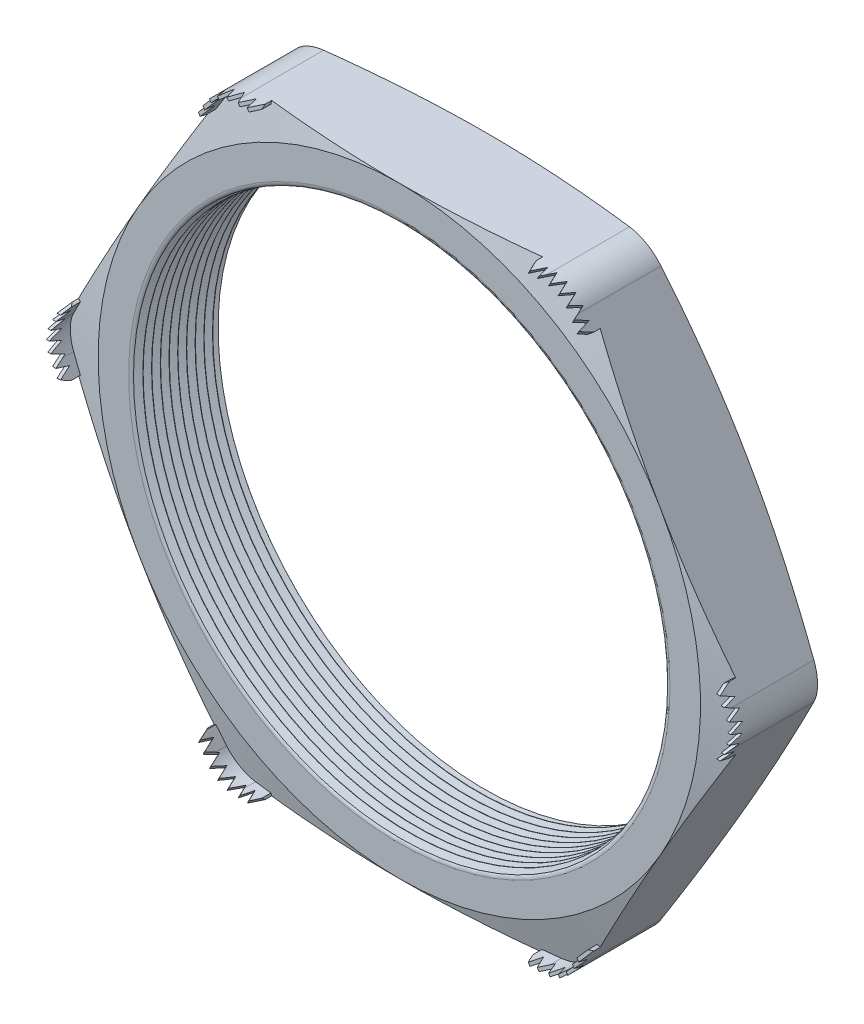
from build123d import *

# Parameters (mm, degrees)
SKETCH1_R          = 9.271
EXTRUDE1_DEPTH     = 3.048
FILLET1_R          = 1.27
FILLET3_R          = 0.2032
LPATTERN1_COUNT    = 10
LPATTERN1_PITCH    = 0.3048
SKETCH4_OUTSIDE_W  = 62.576
SKETCH4_OUTSIDE_H  = 59.708
SKETCH4_OUTSIDE_R  = 10.541
CUT_EXTRUDE1_DEPTH = 4.048
CUT_EXTRUDE1_DRAFT = -75
SKETCH5_OUTSIDE_W  = 62.576
SKETCH5_OUTSIDE_H  = 59.708
SKETCH5_OUTSIDE_R  = 10.541
CUT_EXTRUDE2_DEPTH = 4.0480001
CUT_EXTRUDE2_DRAFT = -75
EXTRUDE2_START     = -0.384301
EXTRUDE2_DEPTH     = 1.400301
CUT_EXTRUDE4_DEPTH = 4.70409549
CIRPATTERN1_COUNT  = 6
CIRPATTERN2_COUNT  = 6


with BuildPart() as part:
    # Sketch1 → Extrude1 (new body)
    with BuildSketch(Plane.XY):
        Polygon((-12.171698375, 0), (-6.085849188, -10.541), (6.085849188, -10.541), (12.171698375, 0), (6.085849188, 10.541), (-6.085849188, 10.541), align=None)
        Circle(SKETCH1_R, mode=Mode.SUBTRACT)
    extrude(amount=EXTRUDE1_DEPTH)

    # Fillet1
    fillet1_edges = [part.edges().sort_by_distance(p)[0] for p in [
        (12.171698375, 0, 1.524),
        (6.085849188, -10.541, 1.524),
        (-6.085849188, -10.541, 1.524),
        (-12.171698375, 0, 1.524),
        (-6.085849188, 10.541, 1.524),
        (6.085849188, 10.541, 1.524),
    ]]
    fillet(fillet1_edges, radius=FILLET1_R)

    # Fillet3
    fillet3_edges = [part.edges().sort_by_distance(p)[0] for p in [
        (-9.271, 0, 0),
        (-9.271, 0, 3.048),
    ]]
    fillet(fillet3_edges, radius=FILLET3_R)

    # Sketch3 → Cut-Revolve1 (revolve, cut)
    with BuildSketch(Plane(origin=(0, 0, 0), x_dir=(1, 0, 0), z_dir=(0, 1, 0)), mode=Mode.PRIVATE) as cut_revolve1_sk:
        Polygon((-9.271, -3.048), (-9.271, -2.754706063), (-9.525, -2.901353032), align=None)
    cut_revolve1 = revolve(cut_revolve1_sk.sketch.rotate(Axis((0, 0, 3.048), (0, 0, -1)), 180), axis=Axis((0, 0, 3.048), (0, 0, -1)), mode=Mode.SUBTRACT)  # turned: the seam where the file's is

    # LPattern1: Cut-Revolve1 ×10
    with Locations(*[(0, 0, -i * LPATTERN1_PITCH) for i in range(1, LPATTERN1_COUNT)]):
        add(cut_revolve1, mode=Mode.SUBTRACT)


with BuildPart() as cut_extrude1_tool:
    # Sketch4 outside → Cut-Extrude1 (with draft: the straight prism first)
    with BuildSketch(Plane(origin=(0, 0, 0), x_dir=(-1, 0, 0), z_dir=(0, 0, -1))):
        Rectangle(SKETCH4_OUTSIDE_W, SKETCH4_OUTSIDE_H)
        Circle(SKETCH4_OUTSIDE_R, mode=Mode.SUBTRACT)
    extrude(amount=-CUT_EXTRUDE1_DEPTH)
    # Cut-Extrude1: the draft: its side faces are tilted about the plane it starts from
    cut_extrude1_sides = [cut_extrude1_tool.faces().sort_by_distance(p)[0] for p in [
        (0, -29.854, 2.024),
        (-31.288, 0, 2.024),
        (0, 29.854, 2.024),
        (31.288, 0, 2.024),
        (10.541, 0, 2.024),
    ]]
    draft(cut_extrude1_sides, Plane(origin=(0, 0, 0), x_dir=(-1, 0, 0), z_dir=(0, 0, -1)), CUT_EXTRUDE1_DRAFT)


with BuildPart() as part_1:
    add(part.part)

    # Cut-Extrude1: cut by cut_extrude1_tool
    add(cut_extrude1_tool.part, mode=Mode.SUBTRACT)


with BuildPart() as cut_extrude2_tool:
    # Sketch5 outside → Cut-Extrude2 (with draft: the straight prism first)
    with BuildSketch(Plane.XY.offset(3.048)):
        Rectangle(SKETCH5_OUTSIDE_W, SKETCH5_OUTSIDE_H)
        Circle(SKETCH5_OUTSIDE_R, mode=Mode.SUBTRACT)
    extrude(amount=-CUT_EXTRUDE2_DEPTH)
    # Cut-Extrude2: the draft: its side faces are tilted about the plane it starts from
    cut_extrude2_sides = [cut_extrude2_tool.faces().sort_by_distance(p)[0] for p in [
        (0, -29.854, 1.02399995),
        (31.288, 0, 1.02399995),
        (0, 29.854, 1.02399995),
        (-31.288, 0, 1.02399995),
        (-10.541, 0, 1.02399995),
    ]]
    draft(cut_extrude2_sides, Plane.XY.offset(3.048), CUT_EXTRUDE2_DRAFT)


with BuildPart() as part_2:
    add(part_1.part)

    # Cut-Extrude2: cut by cut_extrude2_tool
    add(cut_extrude2_tool.part, mode=Mode.SUBTRACT)

    # Sketch2 → Extrude2 (add)
    with BuildSketch(Plane.XY.offset(3.048).offset(EXTRUDE2_START)):
        with BuildLine():
            Line((-5.352614346, 10.541), (-4.743014346, 10.541))
            Line((-4.743014346, 10.541), (-4.743014346, 10.4394))
            Line((-4.743014346, 10.4394), (-5.352614346, 10.4394))
            ThreePointArc((-5.352614346, 10.4394), (-5.936814346, 10.282864082), (-6.364478427, 9.8552))
            Line((-6.364478427, 9.8552), (-6.669278427, 9.327270914))
            Line((-6.669278427, 9.327270914), (-6.757266608, 9.378070914))
            Line((-6.757266608, 9.378070914), (-6.452466608, 9.906))
            ThreePointArc((-6.452466608, 9.906), (-5.987614346, 10.370852263), (-5.352614346, 10.541))
        make_face()
    extrude2 = extrude(amount=EXTRUDE2_DEPTH)

    # Sketch7 → Cut-Extrude4 (cut, through all)
    with BuildSketch(Plane(origin=(-5.706146387, 9.883335457, 0), x_dir=(0.866025404, 0.5, 0), z_dir=(0.5, -0.866025404, 0))):
        Polygon((-1.162929086, 2.9972), (-0.985129086, 3.42392), (-0.807329086, 2.9972), (-0.7112, 3.42392), (-0.5334, 2.9972), (-0.3556, 3.42392), (-0.1778, 2.9972), (0, 3.42392), (0.1778, 2.9972), (0.3556, 3.42392), (0.5334, 2.9972), (0.7112, 3.42392), (0.889, 2.9972), (0.985129086, 3.42392), (1.162929086, 2.9972), (1.162929086, 4.064), (-1.162929086, 4.064), align=None)
    cut_extrude4 = extrude(amount=-CUT_EXTRUDE4_DEPTH, mode=Mode.SUBTRACT)

    # CirPattern1: Extrude2 ×6 about axis
    cirpattern1_axis = Axis((0, 0, 0), (0, 0, 1))
    for i in range(1, CIRPATTERN1_COUNT):
        add(extrude2.rotate(cirpattern1_axis, i * 360 / CIRPATTERN1_COUNT))

    # CirPattern2: Cut-Extrude4 ×6 about axis
    cirpattern2_axis = Axis((0, 0, 0), (0, 0, 1))
    for i in range(1, CIRPATTERN2_COUNT):
        add(cut_extrude4.rotate(cirpattern2_axis, i * 360 / CIRPATTERN2_COUNT), mode=Mode.SUBTRACT)


solid = part_2.part
